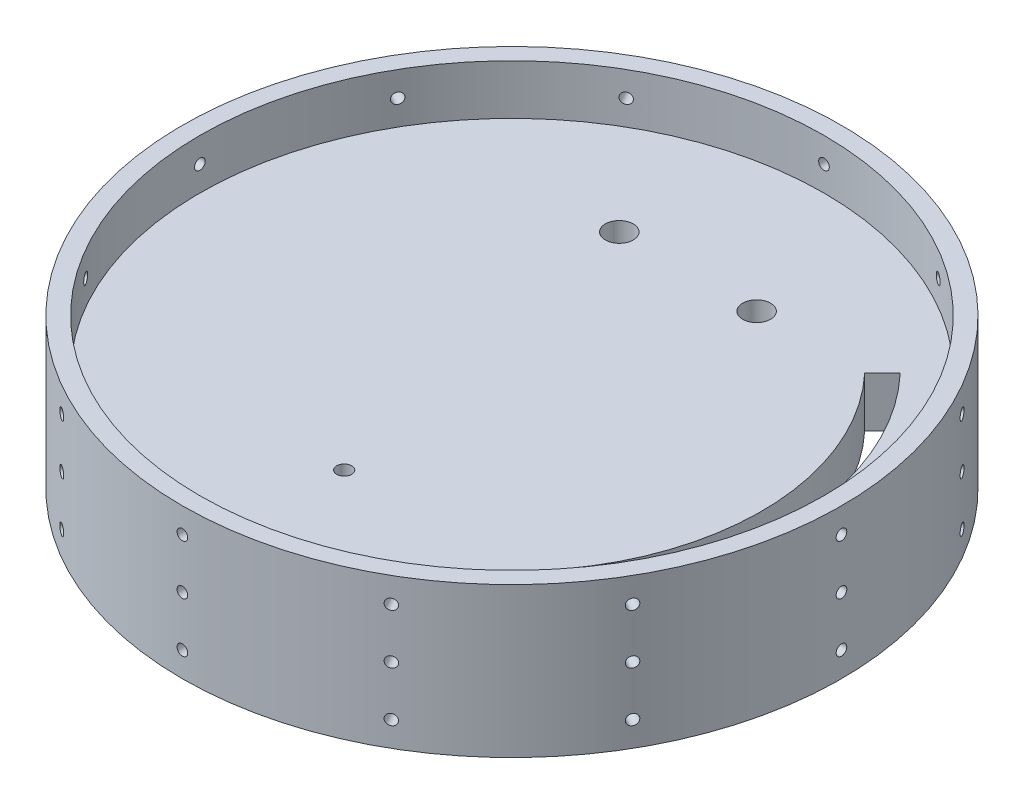
from build123d import *

# Parameters (mm, degrees)
SKETCH1_W            = 127.635
SKETCH1_H            = 127.635
MAIN_PLATE_DEPTH     = 12.7
SKETCH9_R            = 85.725
BOSS_EXTRUDE1_DEPTH  = 12.7
SKETCH10_R           = 97.039626961
SKETCH10_R_2         = 83.82
CUT_EXTRUDE1_DEPTH   = 167.64
SKETCH2_R            = 3.556
U_BOLT_HOLE_DEPTH    = 12.7
U_BOLT_PATTERN_COUNT = 2
U_BOLT_PATTERN_PITCH = 34.925
SKETCH13_R           = 1.905
CUT_EXTRUDE2_DEPTH   = 12.7
CUT_EXTRUDE4_DEPTH   = 15.24
SKETCH18_R           = 83.82
SKETCH18_R_2         = 79.375
BOSS_EXTRUDE2_DEPTH  = 19.05
SKETCH15_R           = 1.35255
CUT_EXTRUDE3_DEPTH   = 15.24
CIRPATTERN1_COUNT    = 12


with BuildPart() as part:
    # Sketch1 → Main Plate (new body)
    with BuildSketch(Plane(origin=(0, 0, 0), x_dir=(1, 0, 0), z_dir=(0, 1, 0))):
        with Locations((63.8175, 63.8175)):
            Rectangle(SKETCH1_W, SKETCH1_H)
    extrude(amount=MAIN_PLATE_DEPTH)

    # Sketch9 → Boss-Extrude1 (add)
    with BuildSketch(Plane(origin=(0, 12.7, 0), x_dir=(1, 0, 0), z_dir=(0, 1, 0))):
        with Locations((63.8175, 63.8175)):
            Circle(SKETCH9_R)
    extrude(amount=-BOSS_EXTRUDE1_DEPTH)

    # Sketch10 → Cut-Extrude1 (cut)
    with BuildSketch(Plane(origin=(0, 12.7, 0), x_dir=(1, 0, 0), z_dir=(0, 1, 0))):
        with Locations((63.8175, 63.8175)):
            Circle(SKETCH10_R)
        with Locations((63.8175, 63.8175)):
            Circle(SKETCH10_R_2, mode=Mode.SUBTRACT)
    extrude(amount=-CUT_EXTRUDE1_DEPTH, mode=Mode.SUBTRACT)

    # Sketch2 → U-Bolt Hole (cut)
    with BuildSketch(Plane(origin=(0, 12.7, 0), x_dir=(1, 0, 0), z_dir=(0, 1, 0))):
        with Locations((46.355, 108.585)):
            Circle(SKETCH2_R)
    u_bolt_hole = extrude(amount=-U_BOLT_HOLE_DEPTH, mode=Mode.SUBTRACT)

    # U-Bolt Pattern: U-Bolt Hole ×2
    with Locations(*[(i * U_BOLT_PATTERN_PITCH, 0, 0) for i in range(1, U_BOLT_PATTERN_COUNT)]):
        add(u_bolt_hole, mode=Mode.SUBTRACT)

    # Sketch13 → Cut-Extrude2 (cut)
    with BuildSketch(Plane(origin=(0, 12.7, 0), x_dir=(1, 0, 0), z_dir=(0, 1, 0))):
        with Locations((63.8175, 21.155768688)):
            Circle(SKETCH13_R)
    extrude(amount=-CUT_EXTRUDE2_DEPTH, mode=Mode.SUBTRACT)

    # Sketch16 → Cut-Extrude4 (cut)
    with BuildSketch(Plane(origin=(0, 12.7, 0), x_dir=(1, 0, 0), z_dir=(0, 1, 0))):
        with BuildLine():
            Line((107.398686311, 20.236313689), (111.888814371, 15.746185629))
            ThreePointArc((111.888814371, 15.746185629), (132.341167201, 64.204063291), (113.191264299, 113.191264299))
            Line((113.191264299, 113.191264299), (108.677336857, 108.677336857))
            ThreePointArc((108.677336857, 108.677336857), (125.968741263, 64.197588818), (107.398686311, 20.236313689))
        make_face()
    extrude(amount=-CUT_EXTRUDE4_DEPTH, mode=Mode.SUBTRACT)

    # Sketch18 → Boss-Extrude2 (add, symmetric)
    with BuildSketch(Plane(origin=(0, 6.35, 0), x_dir=(1, 0, 0), z_dir=(0, 1, 0))):
        with Locations((63.8175, 63.8175)):
            Circle(SKETCH18_R)
        with Locations((63.8175, 63.8175)):
            Circle(SKETCH18_R_2, mode=Mode.SUBTRACT)
    extrude(amount=BOSS_EXTRUDE2_DEPTH, both=True)

    # Sketch15 → Cut-Extrude3 (cut)
    with BuildSketch(Plane.ZY.offset(20.0025)):
        with Locations((-63.8175, 6.35)):
            Circle(SKETCH15_R)
        with Locations((-63.8175, 19.05)):
            Circle(SKETCH15_R)
        with Locations((-63.8175, -6.35)):
            Circle(SKETCH15_R)
    cut_extrude3 = extrude(amount=-CUT_EXTRUDE3_DEPTH, mode=Mode.SUBTRACT)

    # CirPattern1: Cut-Extrude3 ×12 about axis
    cirpattern1_axis = Axis((63.8175, 0, -63.8175), (0, 1, 0))
    for i in range(1, CIRPATTERN1_COUNT):
        add(cut_extrude3.rotate(cirpattern1_axis, i * 360 / CIRPATTERN1_COUNT), mode=Mode.SUBTRACT)


solid = part.part
